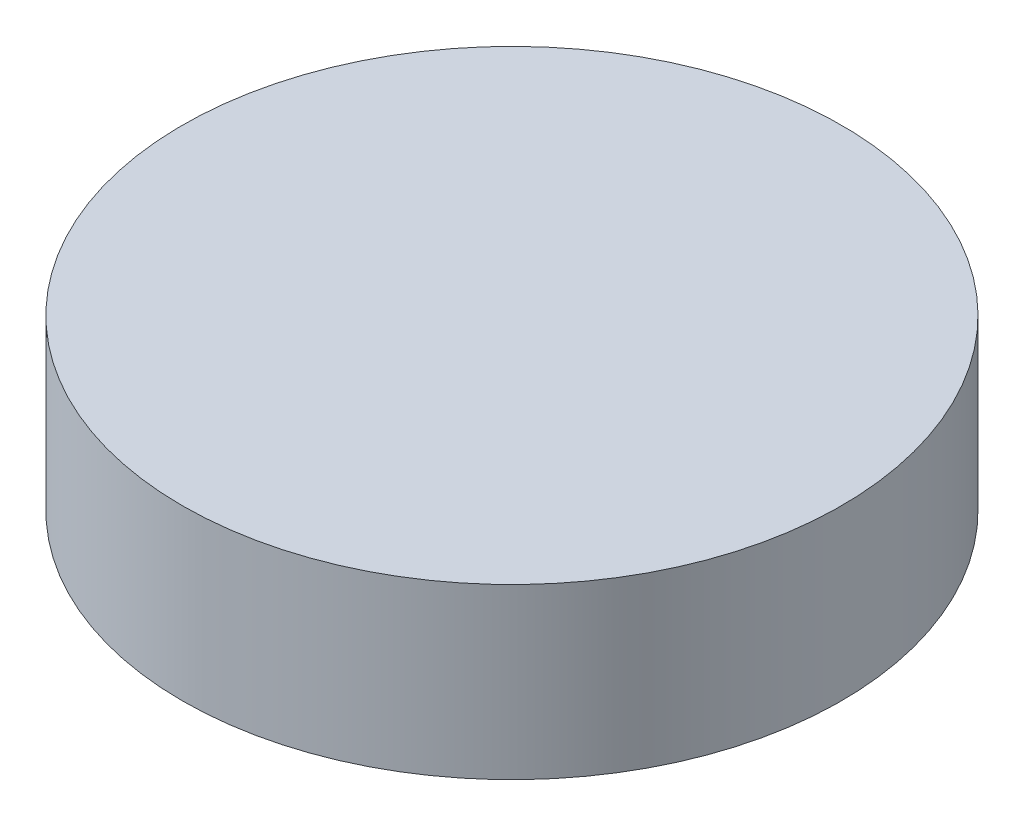
from build123d import *

# Parameters (mm, degrees)
SKETCH1_R           = 19.5
BOSS_EXTRUDE1_DEPTH = 10


with BuildPart() as part:
    # Sketch1 → Boss-Extrude1 (new body)
    with BuildSketch(Plane(origin=(0, 0, 0), x_dir=(1, 0, 0), z_dir=(0, 1, 0))):
        Circle(SKETCH1_R)
    extrude(amount=BOSS_EXTRUDE1_DEPTH)


solid = part.part
